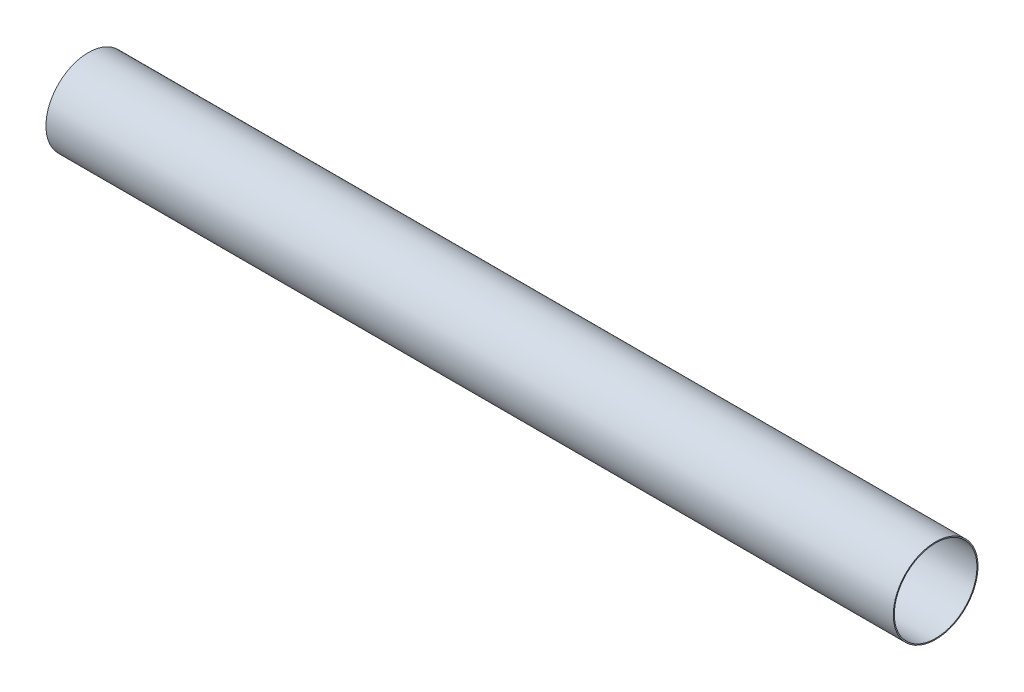
from build123d import *

# Parameters (mm, degrees)
SKETCH1_R           = 152.4
SKETCH1_R_2         = 148.59
BOSS_EXTRUDE1_DEPTH = 3048


with BuildPart() as part:
    # Sketch1 → Boss-Extrude1 (new body)
    with BuildSketch(Plane(origin=(0, 0, 0), x_dir=(0, 0, -1), z_dir=(1, 0, 0))):
        Circle(SKETCH1_R)
        Circle(SKETCH1_R_2, mode=Mode.SUBTRACT)
    extrude(amount=BOSS_EXTRUDE1_DEPTH)


solid = part.part
